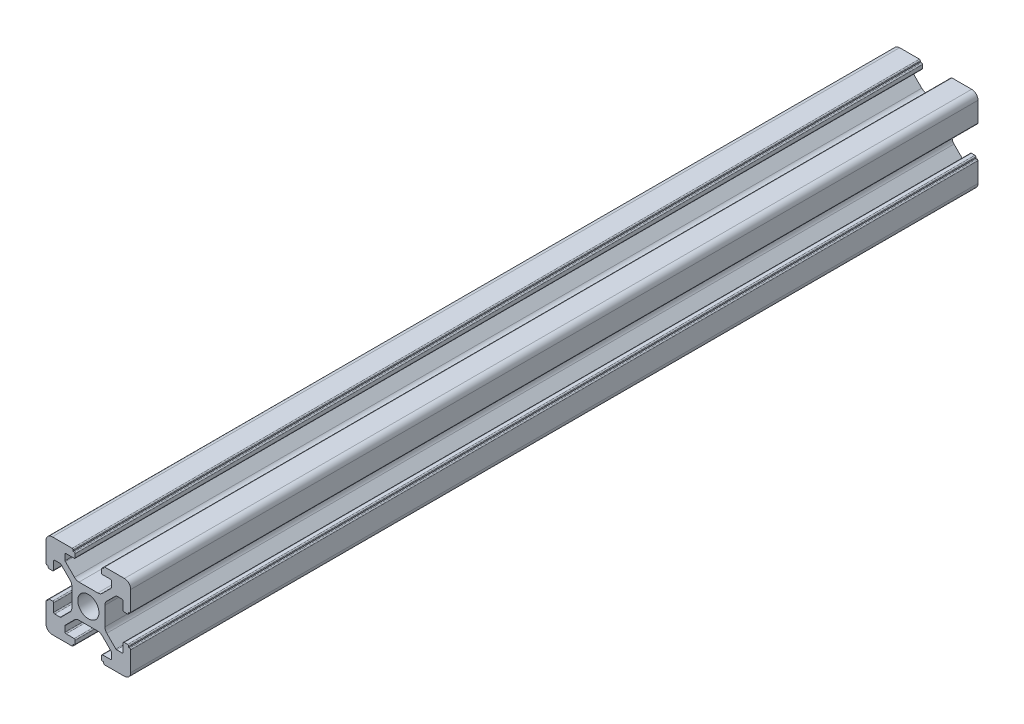
from build123d import *

# Parameters (mm, degrees)
SKETCH_1_R      = 2.5
EXTRUDE_1_DEPTH = 200


with BuildPart() as part:
    # 草图1 → 凸台-拉伸1 (new body)
    with BuildSketch(Plane.XY):
        with BuildLine():
            Line((-8.502261885, -10.002261885), (-3.85, -10.002261885))
            ThreePointArc((-3.85, -10.002261885), (-3.673223305, -9.929038581), (-3.6, -9.752261885))
            Line((-3.6, -9.752261885), (-3.6, -9.502261885))
            Line((-3.6, -9.502261885), (-3.35, -9.502261885))
            ThreePointArc((-3.35, -9.502261885), (-3.173223305, -9.429038581), (-3.1, -9.252261885))
            Line((-3.1, -9.252261885), (-3.1, -8.45))
            ThreePointArc((-3.1, -8.45), (-3.173223305, -8.273223305), (-3.35, -8.2))
            Line((-3.35, -8.2), (-5.25, -8.2))
            ThreePointArc((-5.25, -8.2), (-5.426776695, -8.126776695), (-5.5, -7.95))
            Line((-5.5, -7.95), (-5.5, -6.664213562))
            ThreePointArc((-5.5, -6.664213562), (-5.480969883, -6.568542704), (-5.426776695, -6.487436867))
            Line((-5.426776695, -6.487436867), (-3.278679656, -4.339339828))
            ThreePointArc((-3.278679656, -4.339339828), (-2.792044633, -4.014180701), (-2.218019485, -3.9))
            Line((-2.218019485, -3.9), (2.218019485, -3.9))
            ThreePointArc((2.218019485, -3.9), (2.792044633, -4.014180701), (3.278679656, -4.339339828))
            Line((3.278679656, -4.339339828), (5.426776695, -6.487436867))
            ThreePointArc((5.426776695, -6.487436867), (5.480969883, -6.568542704), (5.5, -6.664213562))
            Line((5.5, -6.664213562), (5.5, -7.95))
            ThreePointArc((5.5, -7.95), (5.426776695, -8.126776695), (5.25, -8.2))
            Line((5.25, -8.2), (3.35, -8.2))
            ThreePointArc((3.35, -8.2), (3.173223305, -8.273223305), (3.1, -8.45))
            Line((3.1, -8.45), (3.1, -9.252261885))
            ThreePointArc((3.1, -9.252261885), (3.173223305, -9.429038581), (3.35, -9.502261885))
            Line((3.35, -9.502261885), (3.6, -9.502261885))
            Line((3.6, -9.502261885), (3.6, -9.752261885))
            ThreePointArc((3.6, -9.752261885), (3.673223305, -9.929038581), (3.85, -10.002261885))
            Line((3.85, -10.002261885), (8.502261885, -10.002261885))
            ThreePointArc((8.502261885, -10.002261885), (9.562922057, -9.562922057), (10.002261885, -8.502261885))
            Line((10.002261885, -8.502261885), (10.002261885, -3.85))
            ThreePointArc((10.002261885, -3.85), (9.929038581, -3.673223305), (9.752261885, -3.6))
            Line((9.752261885, -3.6), (9.502261885, -3.6))
            Line((9.502261885, -3.6), (9.502261885, -3.35))
            ThreePointArc((9.502261885, -3.35), (9.429038581, -3.173223305), (9.252261885, -3.1))
            Line((9.252261885, -3.1), (8.45, -3.1))
            ThreePointArc((8.45, -3.1), (8.273223305, -3.173223305), (8.2, -3.35))
            Line((8.2, -3.35), (8.2, -5.25))
            ThreePointArc((8.2, -5.25), (8.126776695, -5.426776695), (7.95, -5.5))
            Line((7.95, -5.5), (6.664213562, -5.5))
            ThreePointArc((6.664213562, -5.5), (6.568542704, -5.480969883), (6.487436867, -5.426776695))
            Line((6.487436867, -5.426776695), (4.339339828, -3.278679656))
            ThreePointArc((4.339339828, -3.278679656), (4.014180701, -2.792044633), (3.9, -2.218019485))
            Line((3.9, -2.218019485), (3.9, 2.218019485))
            ThreePointArc((3.9, 2.218019485), (4.014180701, 2.792044633), (4.339339828, 3.278679656))
            Line((4.339339828, 3.278679656), (6.487436867, 5.426776695))
            ThreePointArc((6.487436867, 5.426776695), (6.568542704, 5.480969883), (6.664213562, 5.5))
            Line((6.664213562, 5.5), (7.95, 5.5))
            ThreePointArc((7.95, 5.5), (8.126776695, 5.426776695), (8.2, 5.25))
            Line((8.2, 5.25), (8.2, 3.35))
            ThreePointArc((8.2, 3.35), (8.273223305, 3.173223305), (8.45, 3.1))
            Line((8.45, 3.1), (9.252261885, 3.1))
            ThreePointArc((9.252261885, 3.1), (9.429038581, 3.173223305), (9.502261885, 3.35))
            Line((9.502261885, 3.35), (9.502261885, 3.6))
            Line((9.502261885, 3.6), (9.752261885, 3.6))
            ThreePointArc((9.752261885, 3.6), (9.929038581, 3.673223305), (10.002261885, 3.85))
            Line((10.002261885, 3.85), (10.002261885, 8.502261885))
            ThreePointArc((10.002261885, 8.502261885), (9.562922057, 9.562922057), (8.502261885, 10.002261885))
            Line((8.502261885, 10.002261885), (3.85, 10.002261885))
            ThreePointArc((3.85, 10.002261885), (3.673223305, 9.929038581), (3.6, 9.752261885))
            Line((3.6, 9.752261885), (3.6, 9.502261885))
            Line((3.6, 9.502261885), (3.35, 9.502261885))
            ThreePointArc((3.35, 9.502261885), (3.173223305, 9.429038581), (3.1, 9.252261885))
            Line((3.1, 9.252261885), (3.1, 8.45))
            ThreePointArc((3.1, 8.45), (3.173223305, 8.273223305), (3.35, 8.2))
            Line((3.35, 8.2), (5.25, 8.2))
            ThreePointArc((5.25, 8.2), (5.426776695, 8.126776695), (5.5, 7.95))
            Line((5.5, 7.95), (5.5, 6.664213562))
            ThreePointArc((5.5, 6.664213562), (5.480969883, 6.568542704), (5.426776695, 6.487436867))
            Line((5.426776695, 6.487436867), (3.278679656, 4.339339828))
            ThreePointArc((3.278679656, 4.339339828), (2.792044633, 4.014180701), (2.218019485, 3.9))
            Line((2.218019485, 3.9), (-2.218019485, 3.9))
            ThreePointArc((-2.218019485, 3.9), (-2.792044633, 4.014180701), (-3.278679656, 4.339339828))
            Line((-3.278679656, 4.339339828), (-5.426776695, 6.487436867))
            ThreePointArc((-5.426776695, 6.487436867), (-5.480969883, 6.568542704), (-5.5, 6.664213562))
            Line((-5.5, 6.664213562), (-5.5, 7.95))
            ThreePointArc((-5.5, 7.95), (-5.426776695, 8.126776695), (-5.25, 8.2))
            Line((-5.25, 8.2), (-3.35, 8.2))
            ThreePointArc((-3.35, 8.2), (-3.173223305, 8.273223305), (-3.1, 8.45))
            Line((-3.1, 8.45), (-3.1, 9.252261885))
            ThreePointArc((-3.1, 9.252261885), (-3.173223305, 9.429038581), (-3.35, 9.502261885))
            Line((-3.35, 9.502261885), (-3.6, 9.502261885))
            Line((-3.6, 9.502261885), (-3.6, 9.752261885))
            ThreePointArc((-3.6, 9.752261885), (-3.673223305, 9.929038581), (-3.85, 10.002261885))
            Line((-3.85, 10.002261885), (-8.502261885, 10.002261885))
            ThreePointArc((-8.502261885, 10.002261885), (-9.562922057, 9.562922057), (-10.002261885, 8.502261885))
            Line((-10.002261885, 8.502261885), (-10.002261885, 3.85))
            ThreePointArc((-10.002261885, 3.85), (-9.929038581, 3.673223305), (-9.752261885, 3.6))
            Line((-9.752261885, 3.6), (-9.502261885, 3.6))
            Line((-9.502261885, 3.6), (-9.502261885, 3.35))
            ThreePointArc((-9.502261885, 3.35), (-9.429038581, 3.173223305), (-9.252261885, 3.1))
            Line((-9.252261885, 3.1), (-8.45, 3.1))
            ThreePointArc((-8.45, 3.1), (-8.273223305, 3.173223305), (-8.2, 3.35))
            Line((-8.2, 3.35), (-8.2, 5.25))
            ThreePointArc((-8.2, 5.25), (-8.126776695, 5.426776695), (-7.95, 5.5))
            Line((-7.95, 5.5), (-6.664213562, 5.5))
            ThreePointArc((-6.664213562, 5.5), (-6.568542704, 5.480969883), (-6.487436867, 5.426776695))
            Line((-6.487436867, 5.426776695), (-4.339339828, 3.278679656))
            ThreePointArc((-4.339339828, 3.278679656), (-4.014180701, 2.792044633), (-3.9, 2.218019485))
            Line((-3.9, 2.218019485), (-3.9, -2.218019485))
            ThreePointArc((-3.9, -2.218019485), (-4.014180701, -2.792044633), (-4.339339828, -3.278679656))
            Line((-4.339339828, -3.278679656), (-6.487436867, -5.426776695))
            ThreePointArc((-6.487436867, -5.426776695), (-6.568542704, -5.480969883), (-6.664213562, -5.5))
            Line((-6.664213562, -5.5), (-7.95, -5.5))
            ThreePointArc((-7.95, -5.5), (-8.126776695, -5.426776695), (-8.2, -5.25))
            Line((-8.2, -5.25), (-8.2, -3.35))
            ThreePointArc((-8.2, -3.35), (-8.273223305, -3.173223305), (-8.45, -3.1))
            Line((-8.45, -3.1), (-9.252261885, -3.1))
            ThreePointArc((-9.252261885, -3.1), (-9.429038581, -3.173223305), (-9.502261885, -3.35))
            Line((-9.502261885, -3.35), (-9.502261885, -3.6))
            Line((-9.502261885, -3.6), (-9.752261885, -3.6))
            ThreePointArc((-9.752261885, -3.6), (-9.929038581, -3.673223305), (-10.002261885, -3.85))
            Line((-10.002261885, -3.85), (-10.002261885, -8.502261885))
            ThreePointArc((-10.002261885, -8.502261885), (-9.562922057, -9.562922057), (-8.502261885, -10.002261885))
        make_face()
        Circle(SKETCH_1_R, mode=Mode.SUBTRACT)
    extrude(amount=EXTRUDE_1_DEPTH)


solid = part.part
